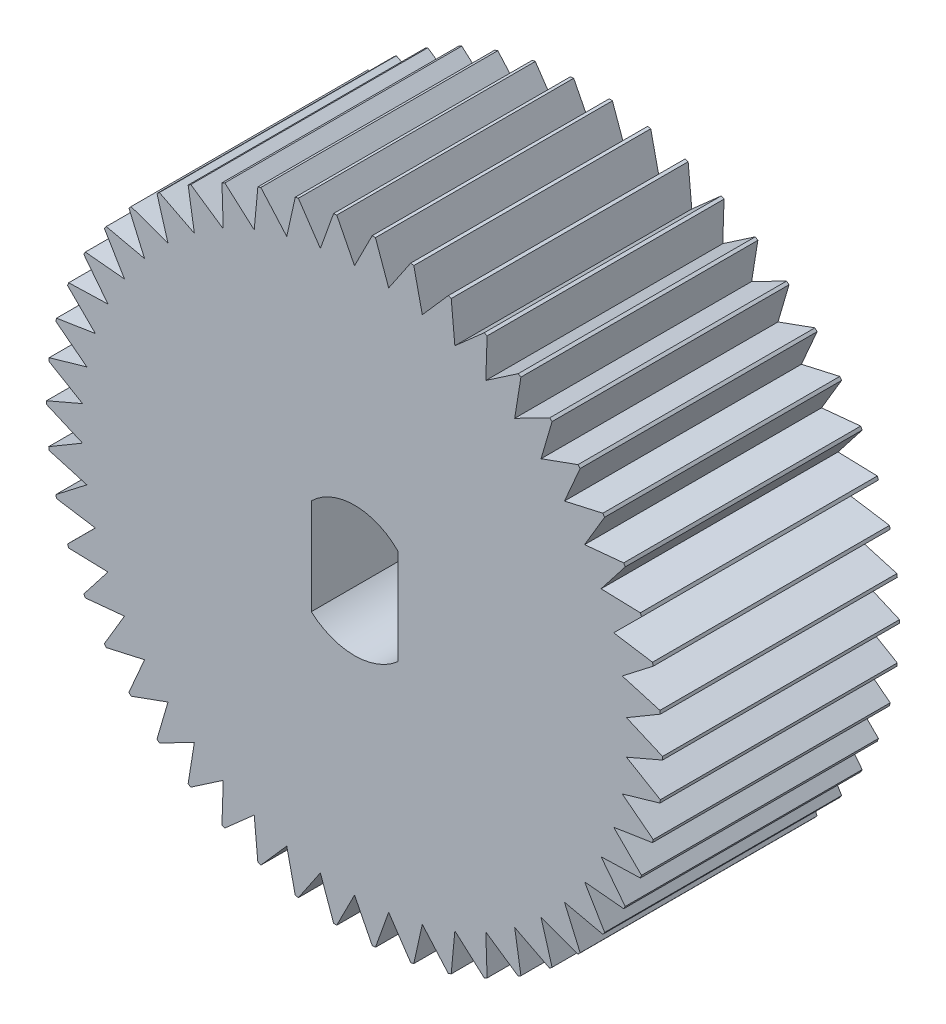
from build123d import *

# Parameters (mm, degrees)
Y_KSEKLIK_EKSTR_ZYON3_DEPTH = 10


with BuildPart() as part:
    # izim1 → Y_kseklik-Ekstr_zyon3 (new body)
    with BuildSketch(Plane.XY):
        with BuildLine():
            ThreePointArc((-4.077196835, 16.919680185), (-4.143452295, 16.924018522), (-4.209729049, 16.928018405))
            Line((-4.209729049, 16.928018405), (-4.959729049, 15.449671053))
            Line((-4.959729049, 15.449671053), (-5.709729049, 16.928018405))
            ThreePointArc((-5.709729049, 16.928018405), (-5.776005803, 16.924018522), (-5.842261263, 16.919680185))
            Line((-5.842261263, 16.919680185), (-6.401061235, 15.358990118))
            Line((-6.401061235, 15.358990118), (-7.330433315, 16.731680335))
            ThreePointArc((-7.330433315, 16.731680335), (-7.395686139, 16.719405312), (-7.460875417, 16.706797173))
            Line((-7.460875417, 16.706797173), (-7.819662752, 15.088377406))
            Line((-7.819662752, 15.088377406), (-8.913750159, 16.333762342))
            ThreePointArc((-8.913750159, 16.333762342), (-8.976949976, 16.313405764), (-9.040044999, 16.292726661))
            Line((-9.040044999, 16.292726661), (-9.193161405, 14.64210064))
            Line((-9.193161405, 14.64210064), (-10.434709727, 15.740539832))
            ThreePointArc((-10.434709727, 15.740539832), (-10.49485984, 15.712422735), (-10.55486556, 15.683998789))
            Line((-10.55486556, 15.683998789), (-10.499896301, 14.027197873))
            Line((-10.499896301, 14.027197873), (-11.86932558, 14.961368278))
            ThreePointArc((-11.86932558, 14.961368278), (-11.925477384, 14.925934084), (-11.981447476, 14.890213559))
            Line((-11.981447476, 14.890213559), (-11.719259451, 13.253366488))
            Line((-11.719259451, 13.253366488), (-13.194972968, 14.00853568))
            ThreePointArc((-13.194972968, 14.00853568), (-13.246240916, 13.966343209), (-13.297292699, 13.923889438))
            Line((-13.297292699, 13.923889438), (-12.832020767, 12.332810268))
            Line((-12.832020767, 12.332810268), (-14.39074564, 12.897068779))
            ThreePointArc((-14.39074564, 12.897068779), (-14.436321206, 12.84878343), (-14.481649561, 12.800265934))
            Line((-14.481649561, 12.800265934), (-13.820631341, 11.280046935))
            Line((-13.820631341, 11.280046935), (-15.437785546, 11.64449607))
            ThreePointArc((-15.437785546, 11.64449607), (-15.476949976, 11.590879332), (-15.51584005, 11.537063263))
            Line((-15.51584005, 11.537063263), (-14.669500193, 10.111679195))
            Line((-14.669500193, 10.111679195), (-16.319580242, 10.270571374))
            ThreePointArc((-16.319580242, 10.270571374), (-16.35171589, 10.212468816), (-16.383554361, 10.154202883))
            Line((-16.383554361, 10.154202883), (-15.365240153, 8.846132906))
            Line((-15.365240153, 8.846132906), (-17.022223299, 8.796962305))
            ThreePointArc((-17.022223299, 8.796962305), (-17.046823366, 8.735290238), (-17.071108124, 8.673493331))
            Line((-17.071108124, 8.673493331), (-15.896878987, 7.503366488))
            Line((-15.896878987, 7.503366488), (-17.534633615, 7.246908556))
            ThreePointArc((-17.534633615, 7.246908556), (-17.551310144, 7.182639586), (-17.567658203, 7.118286279))
            Line((-17.567658203, 7.118286279), (-16.256032433, 6.10455617))
            Line((-16.256032433, 6.10455617), (-17.848730175, 5.644855403))
            ThreePointArc((-17.848730175, 5.644855403), (-17.857220166, 5.579003089), (-17.865373708, 5.513108272))
            Line((-17.865373708, 5.513108272), (-16.437036426, 4.671762027))
            Line((-16.437036426, 4.671762027), (-17.959559487, 4.016068179))
            ThreePointArc((-17.959559487, 4.016068179), (-17.959729049, 3.949671053), (-17.959559487, 3.883273926))
            Line((-17.959559487, 3.883273926), (-16.437036426, 3.227580078))
            Line((-16.437036426, 3.227580078), (-17.865373708, 2.386233833))
            ThreePointArc((-17.865373708, 2.386233833), (-17.857220166, 2.320339016), (-17.848730175, 2.254486703))
            Line((-17.848730175, 2.254486703), (-16.256032433, 1.794785935))
            Line((-16.256032433, 1.794785935), (-17.567658203, 0.781055827))
            ThreePointArc((-17.567658203, 0.781055827), (-17.551310144, 0.716702519), (-17.534633615, 0.652433549))
            Line((-17.534633615, 0.652433549), (-15.896878987, 0.395975617))
            Line((-15.896878987, 0.395975617), (-17.071108124, -0.774151225))
            ThreePointArc((-17.071108124, -0.774151225), (-17.046823366, -0.835948132), (-17.022223299, -0.897620199))
            Line((-17.022223299, -0.897620199), (-15.365240153, -0.9467908))
            Line((-15.365240153, -0.9467908), (-16.383554361, -2.254860778))
            ThreePointArc((-16.383554361, -2.254860778), (-16.35171589, -2.313126711), (-16.319580242, -2.371229269))
            Line((-16.319580242, -2.371229269), (-14.669500193, -2.21233709))
            Line((-14.669500193, -2.21233709), (-15.51584005, -3.637721157))
            ThreePointArc((-15.51584005, -3.637721157), (-15.476949976, -3.691537227), (-15.437785546, -3.745153965))
            Line((-15.437785546, -3.745153965), (-13.820631341, -3.380704829))
            Line((-13.820631341, -3.380704829), (-14.481649561, -4.900923829))
            ThreePointArc((-14.481649561, -4.900923829), (-14.436321206, -4.949441324), (-14.39074564, -4.997726674))
            Line((-14.39074564, -4.997726674), (-12.832020767, -4.433468163))
            Line((-12.832020767, -4.433468163), (-13.297292699, -6.024547333))
            ThreePointArc((-13.297292699, -6.024547333), (-13.246240916, -6.067001103), (-13.194972968, -6.109193575))
            Line((-13.194972968, -6.109193575), (-11.719259451, -5.354024383))
            Line((-11.719259451, -5.354024383), (-11.981447476, -6.990871454))
            ThreePointArc((-11.981447476, -6.990871454), (-11.925477384, -7.026591979), (-11.86932558, -7.062026173))
            Line((-11.86932558, -7.062026173), (-10.499896301, -6.127855768))
            Line((-10.499896301, -6.127855768), (-10.55486556, -7.784656684))
            ThreePointArc((-10.55486556, -7.784656684), (-10.49485984, -7.813080629), (-10.434709727, -7.841197727))
            Line((-10.434709727, -7.841197727), (-9.193161405, -6.742758535))
            Line((-9.193161405, -6.742758535), (-9.040044999, -8.393384556))
            ThreePointArc((-9.040044999, -8.393384556), (-8.976949976, -8.414063659), (-8.913750159, -8.434420237))
            Line((-8.913750159, -8.434420237), (-7.819662752, -7.1890353))
            Line((-7.819662752, -7.1890353), (-7.460875417, -8.807455068))
            ThreePointArc((-7.460875417, -8.807455068), (-7.395686139, -8.820063207), (-7.330433315, -8.832338229))
            Line((-7.330433315, -8.832338229), (-6.401061235, -7.459648012))
            Line((-6.401061235, -7.459648012), (-5.842261263, -9.02033808))
            ThreePointArc((-5.842261263, -9.02033808), (-5.776005803, -9.024676417), (-5.709729049, -9.0286763))
            Line((-5.709729049, -9.0286763), (-4.959729049, -7.550328947))
            Line((-4.959729049, -7.550328947), (-4.209729049, -9.0286763))
            ThreePointArc((-4.209729049, -9.0286763), (-4.143452295, -9.024676417), (-4.077196835, -9.02033808))
            Line((-4.077196835, -9.02033808), (-3.518396863, -7.459648012))
            Line((-3.518396863, -7.459648012), (-2.589024783, -8.832338229))
            ThreePointArc((-2.589024783, -8.832338229), (-2.52377196, -8.820063207), (-2.458582681, -8.807455068))
            Line((-2.458582681, -8.807455068), (-2.099795347, -7.1890353))
            Line((-2.099795347, -7.1890353), (-1.00570794, -8.434420237))
            ThreePointArc((-1.00570794, -8.434420237), (-0.942508122, -8.414063659), (-0.8794131, -8.393384556))
            Line((-0.8794131, -8.393384556), (-0.726296693, -6.742758535))
            Line((-0.726296693, -6.742758535), (0.515251629, -7.841197727))
            ThreePointArc((0.515251629, -7.841197727), (0.575401741, -7.813080629), (0.635407461, -7.784656684))
            Line((0.635407461, -7.784656684), (0.580438203, -6.127855768))
            Line((0.580438203, -6.127855768), (1.949867482, -7.062026173))
            ThreePointArc((1.949867482, -7.062026173), (2.006019285, -7.026591979), (2.061989378, -6.990871454))
            Line((2.061989378, -6.990871454), (1.799801352, -5.354024383))
            Line((1.799801352, -5.354024383), (3.275514869, -6.109193575))
            ThreePointArc((3.275514869, -6.109193575), (3.326782817, -6.067001103), (3.3778346, -6.024547333))
            Line((3.3778346, -6.024547333), (2.912562669, -4.433468163))
            Line((2.912562669, -4.433468163), (4.471287541, -4.997726674))
            ThreePointArc((4.471287541, -4.997726674), (4.516863107, -4.949441324), (4.562191463, -4.900923829))
            Line((4.562191463, -4.900923829), (3.901173243, -3.380704829))
            Line((3.901173243, -3.380704829), (5.518327447, -3.745153965))
            ThreePointArc((5.518327447, -3.745153965), (5.557491878, -3.691537227), (5.596381951, -3.637721157))
            Line((5.596381951, -3.637721157), (4.750042094, -2.21233709))
            Line((4.750042094, -2.21233709), (6.400122143, -2.371229269))
            ThreePointArc((6.400122143, -2.371229269), (6.432257791, -2.313126711), (6.464096263, -2.254860778))
            Line((6.464096263, -2.254860778), (5.445782054, -0.9467908))
            Line((5.445782054, -0.9467908), (7.1027652, -0.897620199))
            ThreePointArc((7.1027652, -0.897620199), (7.127365267, -0.835948132), (7.151650025, -0.774151225))
            Line((7.151650025, -0.774151225), (5.977420888, 0.395975617))
            Line((5.977420888, 0.395975617), (7.615175517, 0.652433549))
            ThreePointArc((7.615175517, 0.652433549), (7.631852045, 0.716702519), (7.648200105, 0.781055827))
            Line((7.648200105, 0.781055827), (6.336574334, 1.794785935))
            Line((6.336574334, 1.794785935), (7.929272076, 2.254486703))
            ThreePointArc((7.929272076, 2.254486703), (7.937762068, 2.320339016), (7.94591561, 2.386233833))
            Line((7.94591561, 2.386233833), (6.517578328, 3.227580078))
            Line((6.517578328, 3.227580078), (8.040101389, 3.883273926))
            ThreePointArc((8.040101389, 3.883273926), (8.04022856, 3.916472381), (8.040270951, 3.949671053))
            ThreePointArc((8.040270951, 3.949671053), (8.04022856, 3.982869724), (8.040101389, 4.016068179))
            Line((8.040101389, 4.016068179), (6.517578328, 4.671762027))
            Line((6.517578328, 4.671762027), (7.94591561, 5.513108272))
            ThreePointArc((7.94591561, 5.513108272), (7.937762068, 5.579003089), (7.929272076, 5.644855403))
            Line((7.929272076, 5.644855403), (6.336574334, 6.10455617))
            Line((6.336574334, 6.10455617), (7.648200105, 7.118286279))
            ThreePointArc((7.648200105, 7.118286279), (7.631852045, 7.182639586), (7.615175517, 7.246908556))
            Line((7.615175517, 7.246908556), (5.977420888, 7.503366488))
            Line((5.977420888, 7.503366488), (7.151650025, 8.673493331))
            ThreePointArc((7.151650025, 8.673493331), (7.127365267, 8.735290238), (7.1027652, 8.796962305))
            Line((7.1027652, 8.796962305), (5.445782054, 8.846132906))
            Line((5.445782054, 8.846132906), (6.464096263, 10.154202883))
            ThreePointArc((6.464096263, 10.154202883), (6.432257791, 10.212468816), (6.400122143, 10.270571374))
            Line((6.400122143, 10.270571374), (4.750042094, 10.111679195))
            Line((4.750042094, 10.111679195), (5.596381951, 11.537063263))
            ThreePointArc((5.596381951, 11.537063263), (5.557491878, 11.590879332), (5.518327447, 11.64449607))
            Line((5.518327447, 11.64449607), (3.901173243, 11.280046935))
            Line((3.901173243, 11.280046935), (4.562191463, 12.800265934))
            ThreePointArc((4.562191463, 12.800265934), (4.516863107, 12.84878343), (4.471287541, 12.897068779))
            Line((4.471287541, 12.897068779), (2.912562669, 12.332810268))
            Line((2.912562669, 12.332810268), (3.3778346, 13.923889438))
            ThreePointArc((3.3778346, 13.923889438), (3.326782817, 13.966343209), (3.275514869, 14.00853568))
            Line((3.275514869, 14.00853568), (1.799801352, 13.253366488))
            Line((1.799801352, 13.253366488), (2.061989378, 14.890213559))
            ThreePointArc((2.061989378, 14.890213559), (2.006019285, 14.925934084), (1.949867482, 14.961368278))
            Line((1.949867482, 14.961368278), (0.580438203, 14.027197873))
            Line((0.580438203, 14.027197873), (0.635407461, 15.683998789))
            ThreePointArc((0.635407461, 15.683998789), (0.575401741, 15.712422735), (0.515251629, 15.740539832))
            Line((0.515251629, 15.740539832), (-0.726296693, 14.64210064))
            Line((-0.726296693, 14.64210064), (-0.8794131, 16.292726661))
            ThreePointArc((-0.8794131, 16.292726661), (-0.942508122, 16.313405764), (-1.00570794, 16.333762342))
            Line((-1.00570794, 16.333762342), (-2.099795347, 15.088377406))
            Line((-2.099795347, 15.088377406), (-2.458582681, 16.706797173))
            ThreePointArc((-2.458582681, 16.706797173), (-2.52377196, 16.719405312), (-2.589024783, 16.731680335))
            Line((-2.589024783, 16.731680335), (-3.518396863, 15.358990118))
            Line((-3.518396863, 15.358990118), (-4.077196835, 16.919680185))
        make_face()
        with BuildLine():
            Line((-6.784729049, 2.281842456), (-6.784729049, 5.943731301))
            ThreePointArc((-6.784729049, 5.943731301), (-4.959729049, 6.699671053), (-3.134729049, 5.943731301))
            Line((-3.134729049, 5.943731301), (-3.134729049, 1.982966557))
            Line((-3.134729049, 1.982966557), (-3.134729049, 1.892518895))
            ThreePointArc((-3.134729049, 1.892518895), (-4.959729049, 1.199671053), (-6.784729049, 1.892518895))
            Line((-6.784729049, 1.892518895), (-6.784729049, 2.281842456))
        make_face(mode=Mode.SUBTRACT)
    extrude(amount=Y_KSEKLIK_EKSTR_ZYON3_DEPTH)


solid = part.part
